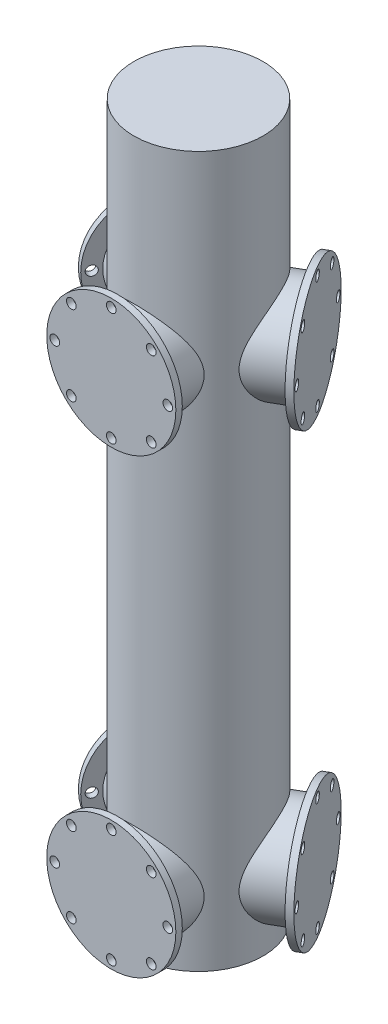
from build123d import *

# Parameters (mm, degrees)
SKETCH1_R           = 20
BOSS_EXTRUDE1_DEPTH = 220
SKETCH2_R           = 15
BOSS_EXTRUDE2_DEPTH = 25
SKETCH3_R           = 20
SKETCH3_R_2         = 1.5
BOSS_EXTRUDE4_DEPTH = 2
CIRPATTERN1_COUNT   = 3


with BuildPart() as part:
    # Sketch1 → Boss-Extrude1 (new body)
    with BuildSketch(Plane(origin=(0, 0, 0), x_dir=(1, 0, 0), z_dir=(0, 1, 0))):
        Circle(SKETCH1_R)
    extrude(amount=BOSS_EXTRUDE1_DEPTH)

    # Sketch2 → Boss-Extrude2 (add)
    with BuildSketch(Plane.XY):
        with Locations((0, 160)):
            Circle(SKETCH2_R)
        with Locations((0, 20)):
            Circle(SKETCH2_R)
    boss_extrude2 = extrude(amount=BOSS_EXTRUDE2_DEPTH)

    # Sketch3 → Boss-Extrude4 (add)
    with BuildSketch(Plane.XY.offset(25)):
        with Locations((0, 160)):
            Circle(SKETCH3_R)
        with Locations((-1.033e-06, 177.5)):
            Circle(SKETCH3_R_2, mode=Mode.SUBTRACT)
        with Locations((12.374367941, 172.374369401)):
            Circle(SKETCH3_R_2, mode=Mode.SUBTRACT)
        with Locations((17.5, 160.000001033)):
            Circle(SKETCH3_R_2, mode=Mode.SUBTRACT)
        with Locations((12.374369401, 147.625632059)):
            Circle(SKETCH3_R_2, mode=Mode.SUBTRACT)
        with Locations((1.033e-06, 142.5)):
            Circle(SKETCH3_R_2, mode=Mode.SUBTRACT)
        with Locations((-12.374367941, 147.625630599)):
            Circle(SKETCH3_R_2, mode=Mode.SUBTRACT)
        with Locations((-17.5, 159.999998967)):
            Circle(SKETCH3_R_2, mode=Mode.SUBTRACT)
        with Locations((-12.374369401, 172.374367941)):
            Circle(SKETCH3_R_2, mode=Mode.SUBTRACT)
        with Locations((0, 20)):
            Circle(SKETCH3_R)
        with Locations((-1.033e-06, 37.5)):
            Circle(SKETCH3_R_2, mode=Mode.SUBTRACT)
        with Locations((12.374367941, 32.374369401)):
            Circle(SKETCH3_R_2, mode=Mode.SUBTRACT)
        with Locations((17.5, 20.000001033)):
            Circle(SKETCH3_R_2, mode=Mode.SUBTRACT)
        with Locations((12.374369401, 7.625632059)):
            Circle(SKETCH3_R_2, mode=Mode.SUBTRACT)
        with Locations((1.033e-06, 2.5)):
            Circle(SKETCH3_R_2, mode=Mode.SUBTRACT)
        with Locations((-12.374367941, 7.625630599)):
            Circle(SKETCH3_R_2, mode=Mode.SUBTRACT)
        with Locations((-17.5, 19.999998967)):
            Circle(SKETCH3_R_2, mode=Mode.SUBTRACT)
        with Locations((-12.374369401, 32.374367941)):
            Circle(SKETCH3_R_2, mode=Mode.SUBTRACT)
    boss_extrude4 = extrude(amount=BOSS_EXTRUDE4_DEPTH)

    # CirPattern1: Boss-Extrude2, Boss-Extrude4 ×3 about axis
    cirpattern1_axis = Axis((0, 0, 0), (0, 1, 0))
    for i in range(1, CIRPATTERN1_COUNT):
        add(boss_extrude2.rotate(cirpattern1_axis, i * 360 / CIRPATTERN1_COUNT))
        add(boss_extrude4.rotate(cirpattern1_axis, i * 360 / CIRPATTERN1_COUNT))


solid = part.part
